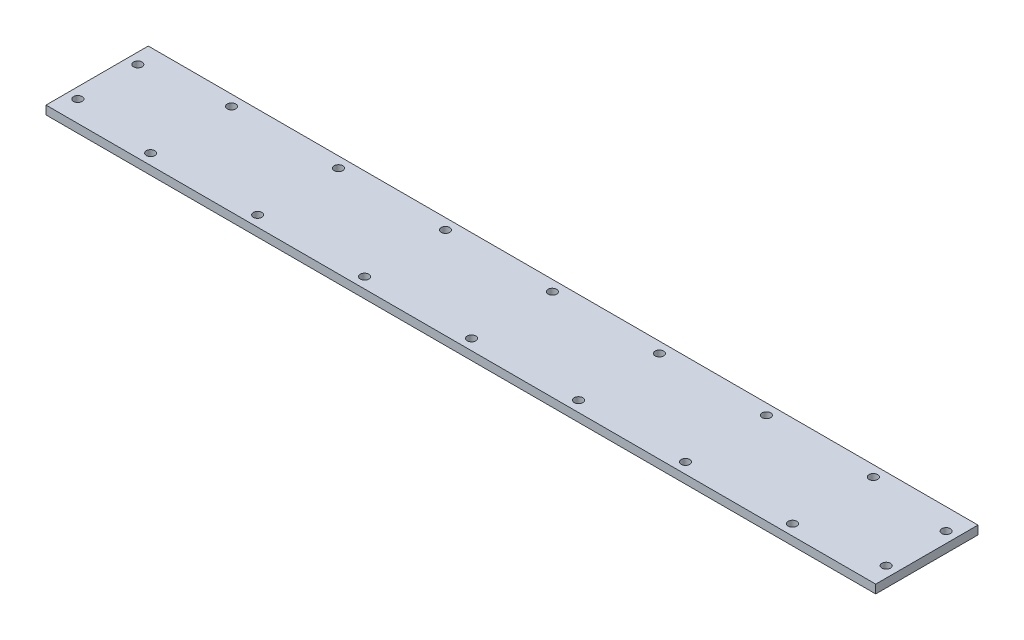
from build123d import *

# Parameters (mm, degrees)
SKETCH1_W           = 193.9
SKETCH1_H           = 23.9
SKETCH1_R           = 1
BOSS_EXTRUDE1_DEPTH = 2


with BuildPart() as part:
    # Sketch1 → Boss-Extrude1 (new body)
    with BuildSketch(Plane(origin=(0, 0, 0), x_dir=(1, 0, 0), z_dir=(0, 1, 0))):
        Rectangle(SKETCH1_W, SKETCH1_H)
        with Locations((-25, 9.45)):
            Circle(SKETCH1_R, mode=Mode.SUBTRACT)
        with Locations((0, 9.45)):
            Circle(SKETCH1_R, mode=Mode.SUBTRACT)
        with Locations((25, 9.45)):
            Circle(SKETCH1_R, mode=Mode.SUBTRACT)
        with Locations((-94.45, 7)):
            Circle(SKETCH1_R, mode=Mode.SUBTRACT)
        with Locations((25, -9.45)):
            Circle(SKETCH1_R, mode=Mode.SUBTRACT)
        with Locations((0, -9.45)):
            Circle(SKETCH1_R, mode=Mode.SUBTRACT)
        with Locations((-25, -9.45)):
            Circle(SKETCH1_R, mode=Mode.SUBTRACT)
        with Locations((-94.45, -7)):
            Circle(SKETCH1_R, mode=Mode.SUBTRACT)
        with Locations((94.45, -7)):
            Circle(SKETCH1_R, mode=Mode.SUBTRACT)
        with Locations((94.45, 7)):
            Circle(SKETCH1_R, mode=Mode.SUBTRACT)
        with Locations((-50, 9.45)):
            Circle(SKETCH1_R, mode=Mode.SUBTRACT)
        with Locations((-75, 9.45)):
            Circle(SKETCH1_R, mode=Mode.SUBTRACT)
        with Locations((75, 9.45)):
            Circle(SKETCH1_R, mode=Mode.SUBTRACT)
        with Locations((50, 9.45)):
            Circle(SKETCH1_R, mode=Mode.SUBTRACT)
        with Locations((75, -9.45)):
            Circle(SKETCH1_R, mode=Mode.SUBTRACT)
        with Locations((50, -9.45)):
            Circle(SKETCH1_R, mode=Mode.SUBTRACT)
        with Locations((-50, -9.45)):
            Circle(SKETCH1_R, mode=Mode.SUBTRACT)
        with Locations((-75, -9.45)):
            Circle(SKETCH1_R, mode=Mode.SUBTRACT)
    extrude(amount=BOSS_EXTRUDE1_DEPTH)


solid = part.part
